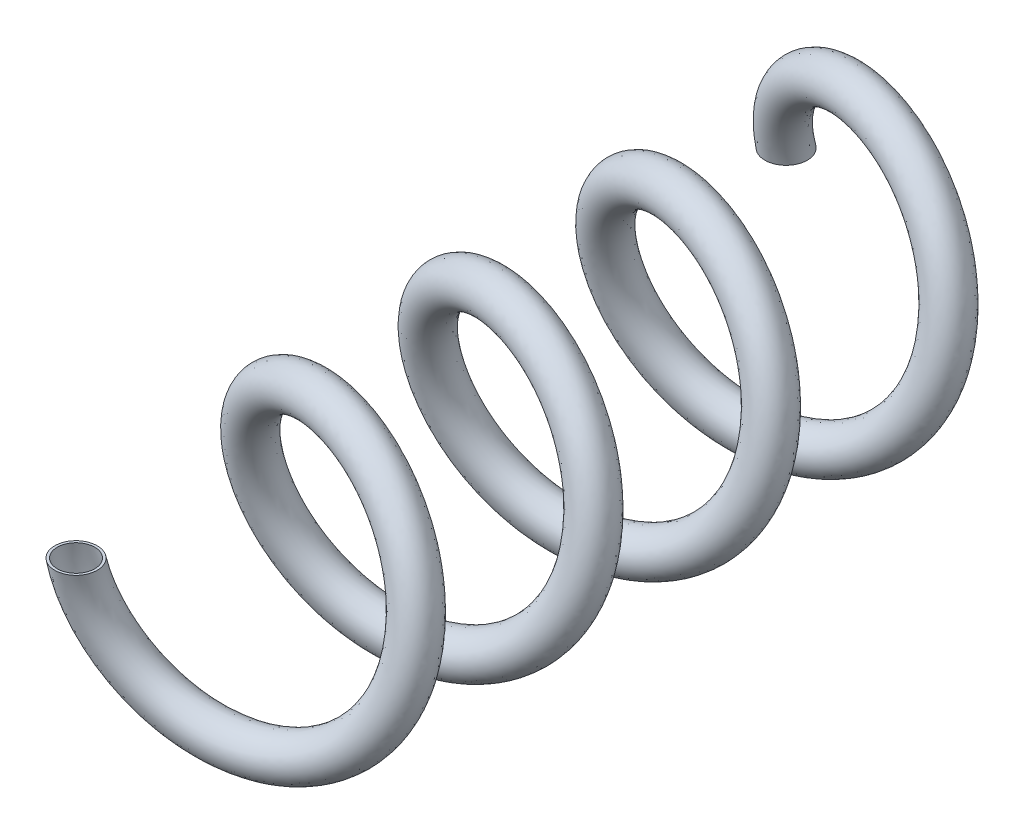
from build123d import *

# Parameters (mm, degrees)
SWEEP1_PITCH       = 50.8
SWEEP1_HEIGHT      = 203.2
SWEEP1_RADIUS      = 35.461389492
SWEEP1_START_ANGLE = -180
SKETCH3_R          = 6.077442414
SKETCH3_R_2        = 5.369120835


with BuildPart() as part:
    # Sweep1: sweep along a helix
    with BuildLine() as sweep1_path:
        add(Helix(SWEEP1_PITCH, SWEEP1_HEIGHT, SWEEP1_RADIUS, center=(0, 0, 0), direction=(0, 0, 1), lefthand=True, mode=Mode.PRIVATE).rotate(Axis((0, 0, 0), (0, 0, 1)), SWEEP1_START_ANGLE))
    # Sketch3 → Sweep1 (sweep)
    with BuildSketch(Plane(origin=(0, 0, 0), x_dir=(1, 0, 0), z_dir=(0, 1, 0))):
        with Locations((-35.461389492, 0)):
            Circle(SKETCH3_R)
        with Locations((-35.461389492, 0)):
            Circle(SKETCH3_R_2, mode=Mode.SUBTRACT)
    sweep(path=sweep1_path.line, is_frenet=True)


solid = part.part
